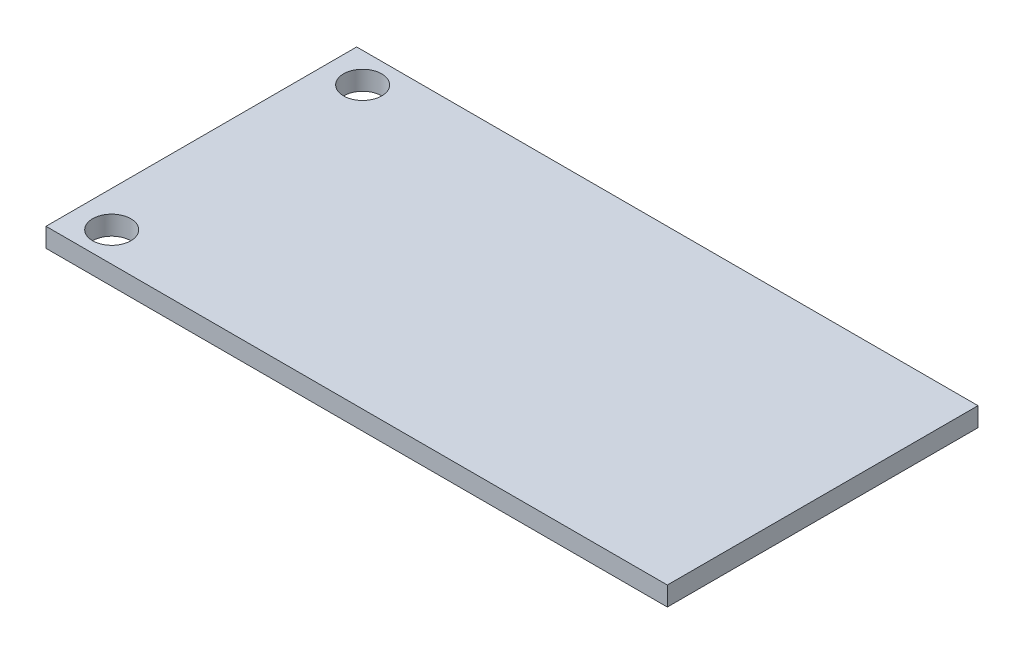
from build123d import *

# Parameters (mm, degrees)
SKETCH1_W           = 52
SKETCH1_H           = 26
SKETCH1_R           = 1.6
BOSS_EXTRUDE1_DEPTH = 1.6


with BuildPart() as part:
    # Sketch1 → Boss-Extrude1 (new body)
    with BuildSketch(Plane(origin=(0, 0, 0), x_dir=(1, 0, 0), z_dir=(0, 1, 0))):
        with Locations((26, 13)):
            Rectangle(SKETCH1_W, SKETCH1_H)
        with Locations((3, 23.5)):
            Circle(SKETCH1_R, mode=Mode.SUBTRACT)
        with Locations((3, 2.5)):
            Circle(SKETCH1_R, mode=Mode.SUBTRACT)
    extrude(amount=BOSS_EXTRUDE1_DEPTH)


solid = part.part
